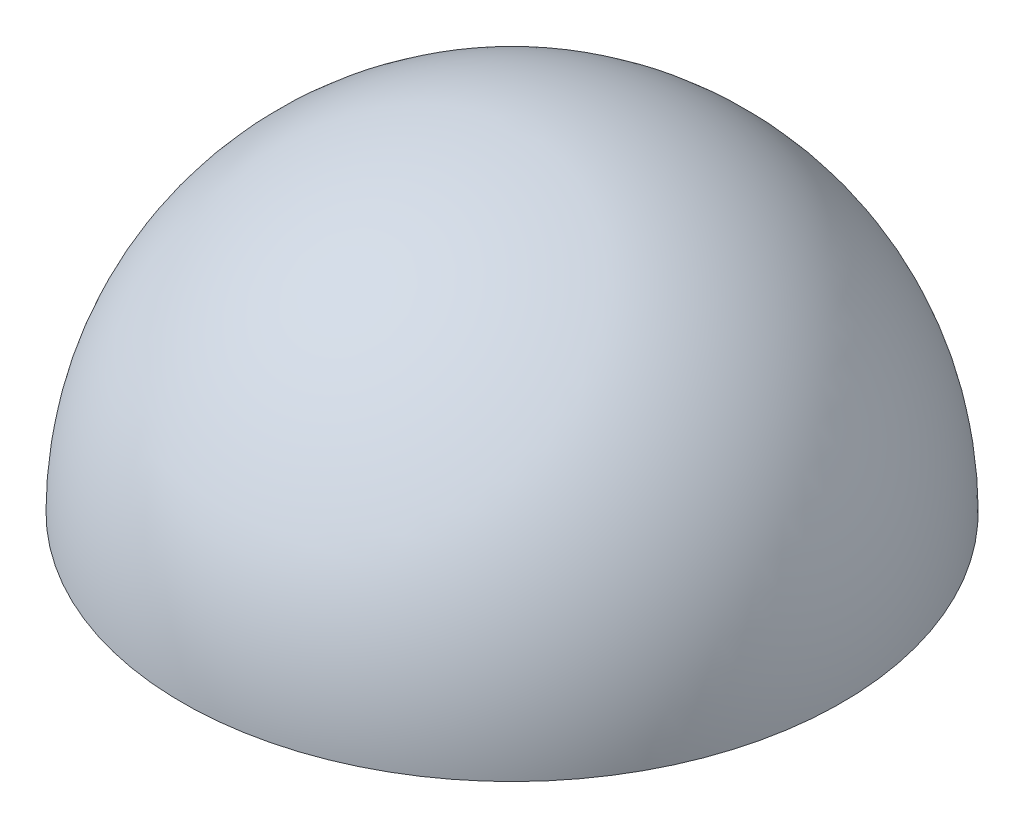
from build123d import *


with BuildPart() as part:
    # Sketch1 → Revolve1 (revolve)
    with BuildSketch(Plane(origin=(0, 0, 0), x_dir=(0, 0, -1), z_dir=(1, 0, 0))):
        with BuildLine():
            Line((-7.033598616, -54.966270669), (-2.033598616, -54.966270669))
            ThreePointArc((-2.033598616, -54.966270669), (-3.498064711, -51.430736763), (-7.033598616, -49.966270669))
            Line((-7.033598616, -49.966270669), (-7.033598616, -54.966270669))
        make_face()
    revolve(axis=Axis((0, -54.966270669, 7.033598616), (0, 1, 0)))


solid = part.part
